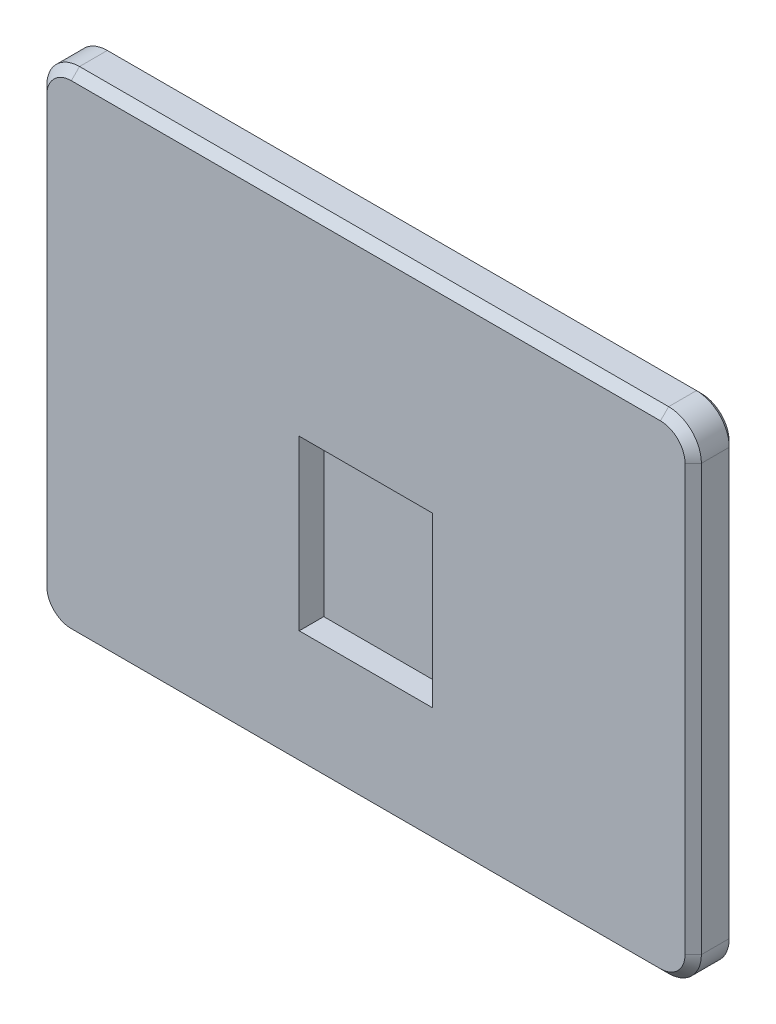
from build123d import *

# Parameters (mm, degrees)
SKETCH1_W           = 40
SKETCH1_H           = 30
BOSS_EXTRUDE1_DEPTH = 2.5
SKETCH2_W           = 8.15
SKETCH2_H           = 10.3
CUT_EXTRUDE1_DEPTH  = 1.5
FILLET1_R           = 2
CHAMFER1_SIZE       = 0.5
CHAMFER2_SIZE       = 0.3


with BuildPart() as part:
    # Sketch1 → Boss-Extrude1 (new body)
    with BuildSketch(Plane.XY):
        Rectangle(SKETCH1_W, SKETCH1_H)
    extrude(amount=BOSS_EXTRUDE1_DEPTH)

    # Sketch2 → Cut-Extrude1 (cut)
    with BuildSketch(Plane.XY.offset(2.5)):
        with Locations((0, -2.5)):
            Rectangle(SKETCH2_W, SKETCH2_H)
    extrude(amount=-CUT_EXTRUDE1_DEPTH, mode=Mode.SUBTRACT)

    # Fillet1
    fillet1_edges = [part.edges().sort_by_distance(p)[0] for p in [
        (20, -15, 1.25),
        (-20, -15, 1.25),
        (-20, 15, 1.25),
        (20, 15, 1.25),
    ]]
    fillet(fillet1_edges, radius=FILLET1_R)

    # Chamfer1
    chamfer1_edges = [part.edges().sort_by_distance(p)[0] for p in [
        (0, -15, 2.5),
        (-20, 0, 2.5),
        (20, 0, 2.5),
        (0, 15, 2.5),
        (19.414213562, 14.414213562, 2.5),
        (-19.414213562, 14.414213562, 2.5),
        (19.414213562, -14.414213562, 2.5),
        (-19.414213562, -14.414213562, 2.5),
    ]]
    chamfer(chamfer1_edges, length=CHAMFER1_SIZE)

    # Chamfer2
    chamfer2_edges = [part.edges().sort_by_distance(p)[0] for p in [
        (0, -15, 0),
        (20, 0, 0),
        (-20, 0, 0),
        (0, 15, 0),
        (19.414213562, 14.414213562, 0),
        (-19.414213562, 14.414213562, 0),
        (19.414213562, -14.414213562, 0),
        (-19.414213562, -14.414213562, 0),
    ]]
    chamfer(chamfer2_edges, length=CHAMFER2_SIZE)


solid = part.part
